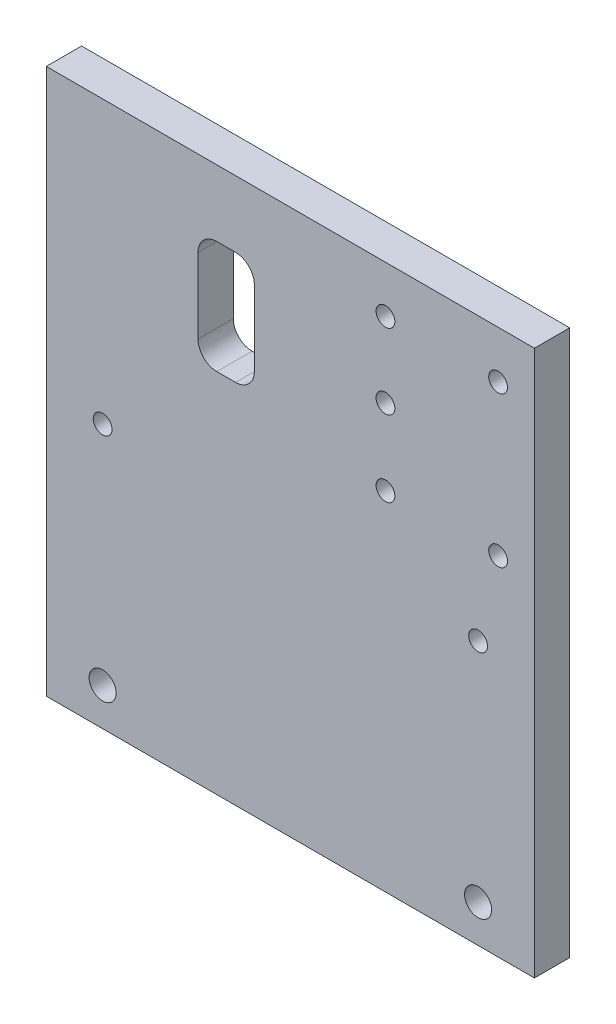
from build123d import *

# Parameters (mm, degrees)
SKETCH1_W           = 130
SKETCH1_H           = 145.26
SKETCH1_R           = 3.6
SKETCH1_R_2         = 2.5
BOSS_EXTRUDE1_DEPTH = 9.4
SKETCH2_W           = 15
SKETCH2_H           = 30
CUT_EXTRUDE1_DEPTH  = 10.4
FILLET1_R           = 5


with BuildPart() as part:
    # Sketch1 → Boss-Extrude1 (new body)
    with BuildSketch(Plane.XY):
        with Locations((50, 62.63)):
            Rectangle(SKETCH1_W, SKETCH1_H)
        Circle(SKETCH1_R, mode=Mode.SUBTRACT)
        with Locations((0, 60.26)):
            Circle(SKETCH1_R_2, mode=Mode.SUBTRACT)
        with Locations((100, 60.26)):
            Circle(SKETCH1_R_2, mode=Mode.SUBTRACT)
        with Locations((100, 0)):
            Circle(SKETCH1_R, mode=Mode.SUBTRACT)
        with Locations((75.33, 82.555)):
            Circle(SKETCH1_R_2, mode=Mode.SUBTRACT)
        with Locations((105.33, 82.555)):
            Circle(SKETCH1_R_2, mode=Mode.SUBTRACT)
        with Locations((105.33, 122.635)):
            Circle(SKETCH1_R_2, mode=Mode.SUBTRACT)
        with Locations((75.33, 102.766411568)):
            Circle(SKETCH1_R_2, mode=Mode.SUBTRACT)
        with Locations((75.33, 122.766411568)):
            Circle(SKETCH1_R_2, mode=Mode.SUBTRACT)
    extrude(amount=BOSS_EXTRUDE1_DEPTH)

    # Sketch2 → Cut-Extrude1 (cut, through all)
    with BuildSketch(Plane(origin=(0, 0, 0), x_dir=(-1, 0, 0), z_dir=(0, 0, -1))):
        with Locations((-32.90754614, 102.570367495)):
            Rectangle(SKETCH2_W, SKETCH2_H)
    extrude(amount=-CUT_EXTRUDE1_DEPTH, mode=Mode.SUBTRACT)

    # Fillet1
    fillet1_edges = [part.edges().sort_by_distance(p)[0] for p in [
        (40.40754614, 87.570367495, 4.7),
        (40.40754614, 117.570367495, 4.7),
        (25.40754614, 117.570367495, 4.7),
        (25.40754614, 87.570367495, 4.7),
    ]]
    fillet(fillet1_edges, radius=FILLET1_R)


solid = part.part
